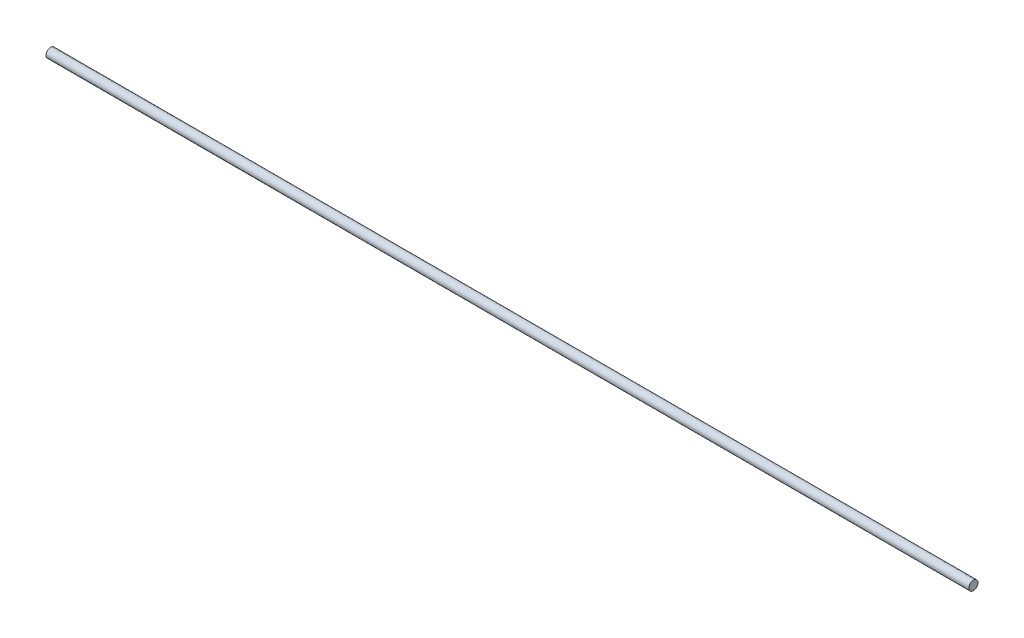
from build123d import *

# Parameters (mm, degrees)
SKETCH3_R           = 1.5
BOSS_EXTRUDE2_DEPTH = 300


with BuildPart() as part:
    # Sketch3 → Boss-Extrude2 (new body)
    with BuildSketch(Plane(origin=(0, 0, 0), x_dir=(0, 0, -1), z_dir=(1, 0, 0))):
        Circle(SKETCH3_R)
    extrude(amount=BOSS_EXTRUDE2_DEPTH)


solid = part.part
